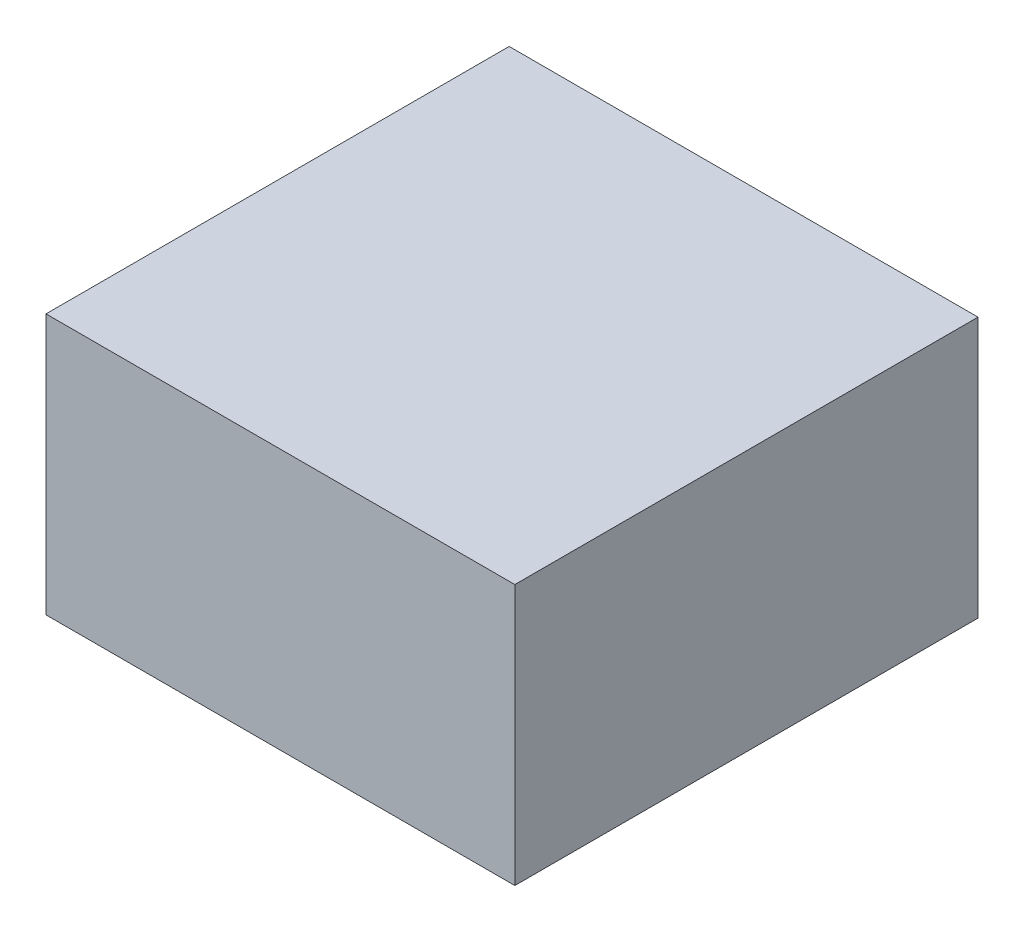
from build123d import *

# Parameters (mm, degrees)
SKETCH1_W                     = 110
SKETCH1_H                     = 108.6724
SCROD_AND_CARRIERS_DEPTH      = 48.1652
SCROD_AND_CARRIERS_DEPTH_BACK = 13


with BuildPart() as part:
    # Sketch1 → SCROD-and-carriers (new body, two sides)
    with BuildSketch(Plane(origin=(0, 0, 0), x_dir=(1, 0, 0), z_dir=(0, 1, 0))) as scrod_and_carriers_sk:
        with Locations((55, 39.3362)):
            Rectangle(SKETCH1_W, SKETCH1_H)
    extrude(amount=SCROD_AND_CARRIERS_DEPTH)
    extrude(scrod_and_carriers_sk.sketch, amount=-SCROD_AND_CARRIERS_DEPTH_BACK)


solid = part.part
